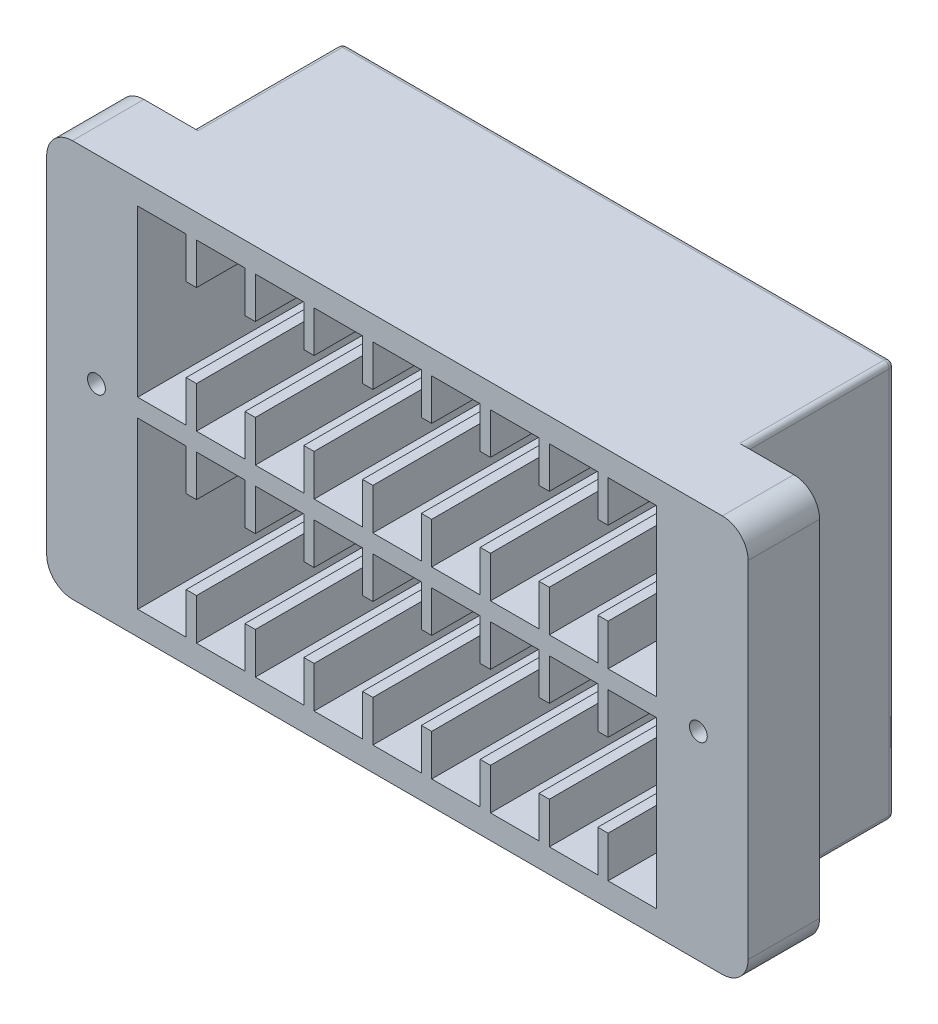
from build123d import *

# Parameters (mm, degrees)
SKETCH1_W                = 136
SKETCH1_H                = 77
SKETCH1_R                = 1.725
BOSS_EXTRUDE1_DEPTH      = 7.85
BOSS_EXTRUDE1_DEPTH_BACK = 6
SKETCH2_W                = 107
SKETCH2_H                = 77
BOSS_EXTRUDE2_DEPTH      = 29
CUT_EXTRUDE1_DEPTH       = 32.5
SKETCH4_W                = 2
SKETCH4_H                = 8
BOSS_EXTRUDE3_DEPTH      = 32.5
FILLET1_R                = 5
FILLET4_R                = 1


with BuildPart() as part:
    # Sketch1 → Boss-Extrude1 (new body, two sides)
    with BuildSketch(Plane.XY) as boss_extrude1_sk:
        Rectangle(SKETCH1_W, SKETCH1_H)
        with Locations((-58.35, 0)):
            Circle(SKETCH1_R, mode=Mode.SUBTRACT)
        with Locations((58.35, 0)):
            Circle(SKETCH1_R, mode=Mode.SUBTRACT)
    extrude(amount=BOSS_EXTRUDE1_DEPTH)
    extrude(boss_extrude1_sk.sketch, amount=-BOSS_EXTRUDE1_DEPTH_BACK)

    # Sketch2 → Boss-Extrude2 (add)
    with BuildSketch(Plane(origin=(0, 0, -6), x_dir=(-1, 0, 0), z_dir=(0, 0, -1))):
        Rectangle(SKETCH2_W, SKETCH2_H)
    extrude(amount=BOSS_EXTRUDE2_DEPTH)

    # Sketch3 → Cut-Extrude1 (cut)
    with BuildSketch(Plane.XY.offset(7.85)):
        Polygon((-38.95, 33.85), (-38.95, 25.85), (-40.95, 25.85), (-40.95, 33.85), (-50.35, 33.85), (-50.35, 1.75), (50.25, 1.75), (50.25, 33.85), (40.85, 33.85), (40.85, 25.85), (38.85, 25.85), (38.85, 33.85), (29.45, 33.85), (29.45, 25.85), (27.45, 25.85), (27.45, 33.85), (18.05, 33.85), (18.05, 25.85), (16.05, 25.85), (16.05, 33.85), (6.65, 33.85), (6.65, 25.85), (4.65, 25.85), (4.65, 33.85), (-4.75, 33.85), (-4.75, 25.85), (-6.75, 25.85), (-6.75, 33.85), (-16.15, 33.85), (-16.15, 25.85), (-18.15, 25.85), (-18.15, 33.85), (-27.55, 33.85), (-27.55, 25.85), (-29.55, 25.85), (-29.55, 33.85), align=None)
    cut_extrude1 = extrude(amount=-CUT_EXTRUDE1_DEPTH, mode=Mode.SUBTRACT)

    # Mirror1: Cut-Extrude1 across plane
    add(cut_extrude1.mirror(Plane.ZX), mode=Mode.SUBTRACT)

    # Sketch4 → Boss-Extrude3 (add)
    with BuildSketch(Plane.XY.offset(7.85)):
        with Locations((-39.95, 5.75)):
            Rectangle(SKETCH4_W, SKETCH4_H)
        with Locations((-28.55, 5.75)):
            Rectangle(SKETCH4_W, SKETCH4_H)
        with Locations((-17.15, 5.75)):
            Rectangle(SKETCH4_W, SKETCH4_H)
        with Locations((-5.75, 5.75)):
            Rectangle(SKETCH4_W, SKETCH4_H)
        with Locations((5.65, 5.75)):
            Rectangle(SKETCH4_W, SKETCH4_H)
        with Locations((17.05, 5.75)):
            Rectangle(SKETCH4_W, SKETCH4_H)
        with Locations((28.45, 5.75)):
            Rectangle(SKETCH4_W, SKETCH4_H)
        with Locations((39.85, 5.75)):
            Rectangle(SKETCH4_W, SKETCH4_H)
    boss_extrude3 = extrude(amount=-BOSS_EXTRUDE3_DEPTH)

    # Mirror2: Boss-Extrude3 across plane
    add(boss_extrude3.mirror(Plane.ZX))

    # Fillet1
    fillet1_edges = [part.edges().sort_by_distance(p)[0] for p in [
        (-68, 38.5, 0.925),
        (68, 38.5, 0.925),
        (68, -38.5, 0.925),
        (-68, -38.5, 0.925),
    ]]
    fillet(fillet1_edges, radius=FILLET1_R)

    # Fillet4
    fillet4_edges = [part.edges().sort_by_distance(p)[0] for p in [
        (53.5, 38.5, -20.5),
        (53.5, -38.5, -20.5),
        (-53.5, -38.5, -20.5),
        (-53.5, 38.5, -20.5),
        (53.5, 0, -35),
        (0, -38.5, -35),
        (-53.5, 0, -35),
        (0, 38.5, -35),
    ]]
    fillet(fillet4_edges, radius=FILLET4_R)


solid = part.part
